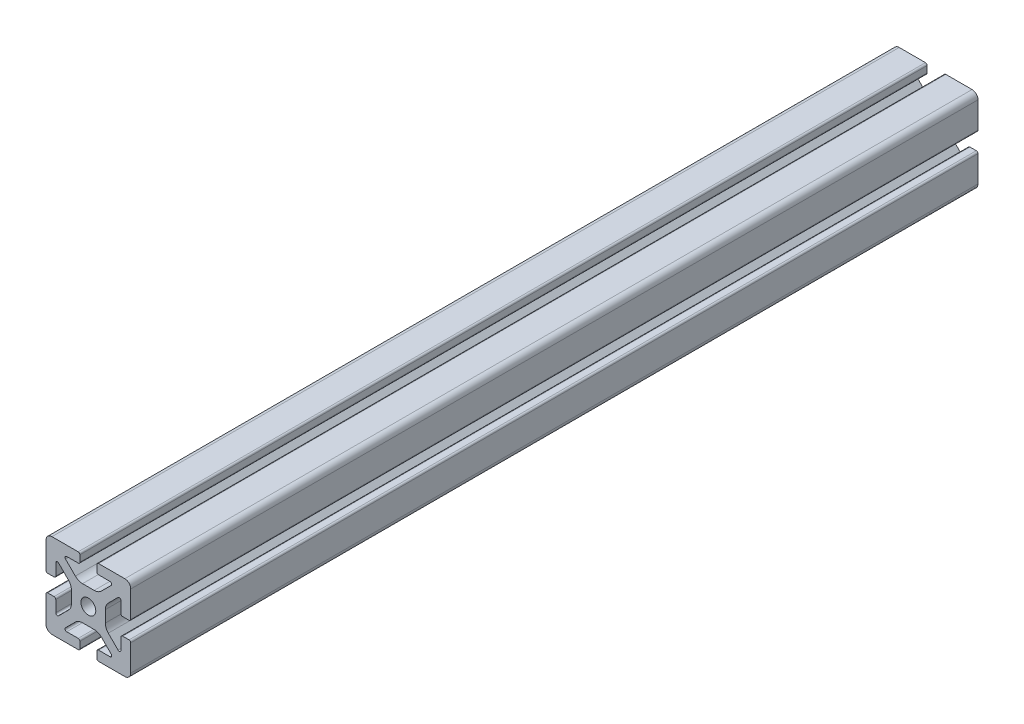
from build123d import *

# Parameters (mm, degrees)
BOSS_EXTRUDE1_DEPTH = 200


with BuildPart() as part:
    # Sketch4 → Boss-Extrude1 (new body, symmetric)
    with BuildSketch(Plane.XY):
        with BuildLine():
            Line((4.8, -20), (17.2, -20))
            ThreePointArc((17.2, -20), (19.179898987, -19.179898987), (20, -17.2))
            Line((20, -17.2), (20, -4.8))
            ThreePointArc((20, -4.8), (19.765685425, -4.234314575), (19.2, -4))
            Line((19.2, -4), (16.190663761, -4))
            ThreePointArc((16.190663761, -4), (15.624978336, -4.234314575), (15.390663761, -4.8))
            Line((15.390663761, -4.8), (15.390663761, -10.2))
            ThreePointArc((15.390663761, -10.2), (14.896810507, -10.939103626), (14.024978336, -10.765685425))
            Line((14.024978336, -10.765685425), (9.40588745, -6.146594539))
            ThreePointArc((9.40588745, -6.146594539), (8.365378244, -4.589362465), (8, -2.752481989))
            Line((8, -2.752481989), (8, 0))
            Line((8, 0), (3.5, 0))
            ThreePointArc((3.5, 0), (2.474873734, -2.474873734), (0, -3.5))
            Line((0, -3.5), (0, -8))
            Line((0, -8), (2.752481989, -8))
            ThreePointArc((2.752481989, -8), (4.589362465, -8.365378244), (6.146594539, -9.40588745))
            Line((6.146594539, -9.40588745), (10.765685425, -14.024978336))
            ThreePointArc((10.765685425, -14.024978336), (10.939103626, -14.896810507), (10.2, -15.390663761))
            Line((10.2, -15.390663761), (4.8, -15.390663761))
            ThreePointArc((4.8, -15.390663761), (4.234314575, -15.624978336), (4, -16.190663761))
            Line((4, -16.190663761), (4, -19.2))
            ThreePointArc((4, -19.2), (4.234314575, -19.765685425), (4.8, -20))
        make_face()
    extrude(amount=BOSS_EXTRUDE1_DEPTH, both=True)

    # Mirror1: part across plane


with BuildPart() as part_1:
    add(part.part)
    add(part.part.mirror(Plane(origin=(0, 0, 0), x_dir=(0, 0, 1), z_dir=(1, 0, 0))))

    # Mirror2: part across plane


with BuildPart() as part_2:
    add(part_1.part)
    add(part_1.part.mirror(Plane.ZX))


solid = part_2.part
